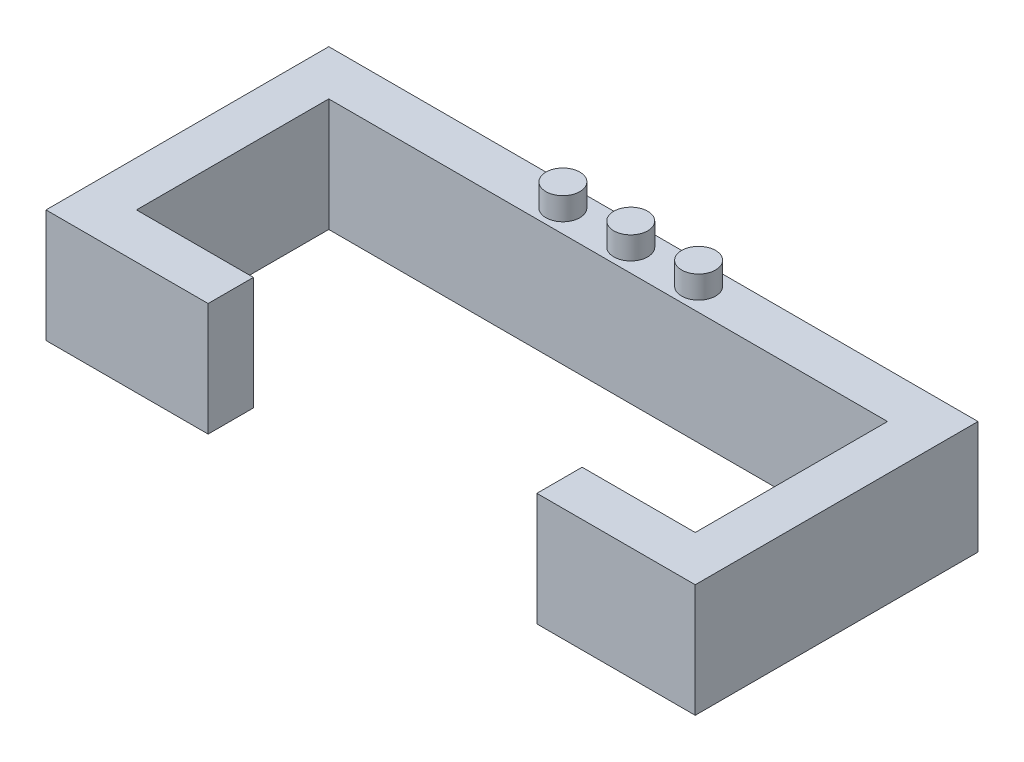
from build123d import *

# Parameters (mm, degrees)
BOSS_EXTRUDE1_DEPTH = 5
SKETCH2_R           = 0.75
BOSS_EXTRUDE4_DEPTH = 1


with BuildPart() as part:
    # Sketch1 → Boss-Extrude1 (new body)
    with BuildSketch(Plane(origin=(0, 0, 0), x_dir=(1, 0, 0), z_dir=(0, 1, 0))):
        Polygon((-12.35, 1.5), (-12.35, 7), (12.35, 7), (12.35, 1.5), (12.35, -1.5), (7.35, -1.5), (7.35, -3.5), (14.35, -3.5), (14.35, 9), (-14.35, 9), (-14.35, -3.5), (-7.182955123, -3.5), (-7.182955123, -1.5), (-12.35, -1.5), align=None)
    extrude(amount=BOSS_EXTRUDE1_DEPTH)

    # Sketch2 → Boss-Extrude4 (add)
    with BuildSketch(Plane(origin=(0, 5, 0), x_dir=(1, 0, 0), z_dir=(0, 1, 0))):
        with Locations((0, 8)):
            Circle(SKETCH2_R)
        with Locations((-3, 8)):
            Circle(SKETCH2_R)
        with Locations((3, 8)):
            Circle(SKETCH2_R)
    extrude(amount=BOSS_EXTRUDE4_DEPTH)


solid = part.part
